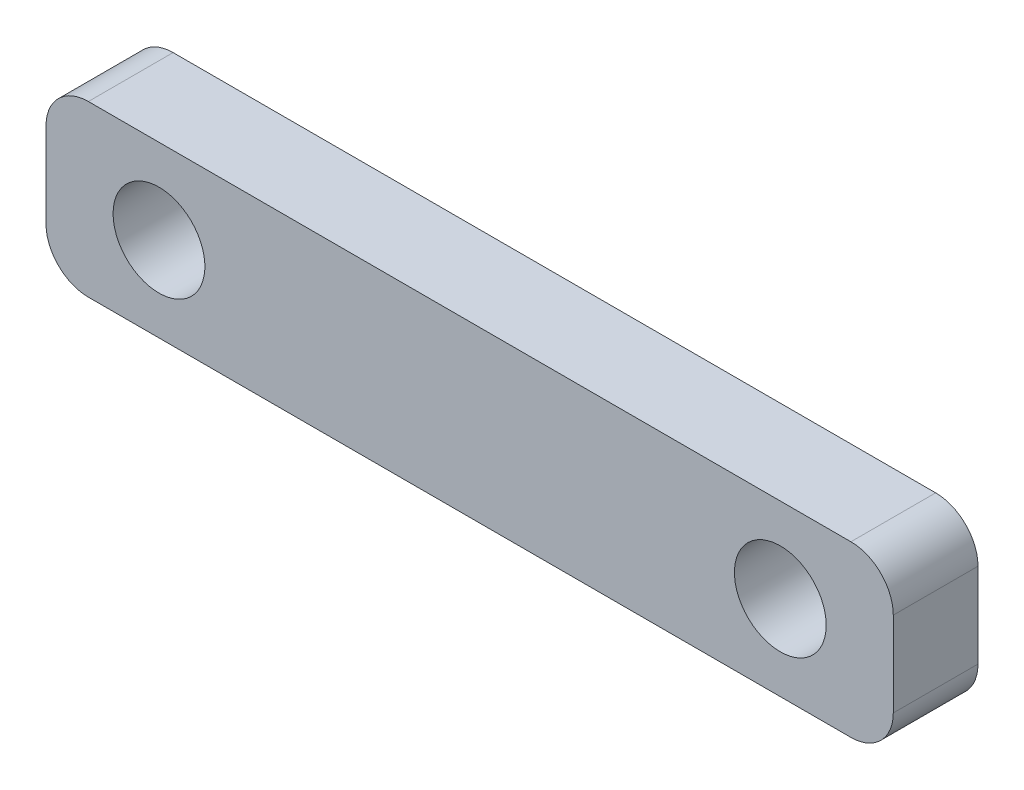
from build123d import *

# Parameters (mm, degrees)
SKETCH1_R          = 3.25
BASE_EXTRUDE_DEPTH = 6


with BuildPart() as part:
    # Sketch1 → Base-Extrude (new body)
    with BuildSketch(Plane.XY):
        with BuildLine():
            Line((-27, -6), (27, -6))
            ThreePointArc((27, -6), (29.121320344, -5.121320344), (30, -3))
            Line((30, -3), (30, 3))
            ThreePointArc((30, 3), (29.121320344, 5.121320344), (27, 6))
            Line((27, 6), (-27, 6))
            ThreePointArc((-27, 6), (-29.121320344, 5.121320344), (-30, 3))
            Line((-30, 3), (-30, -3))
            ThreePointArc((-30, -3), (-29.121320344, -5.121320344), (-27, -6))
        make_face()
        with Locations((22, 0)):
            Circle(SKETCH1_R, mode=Mode.SUBTRACT)
        with Locations((-22, 0)):
            Circle(SKETCH1_R, mode=Mode.SUBTRACT)
    extrude(amount=BASE_EXTRUDE_DEPTH)


solid = part.part
